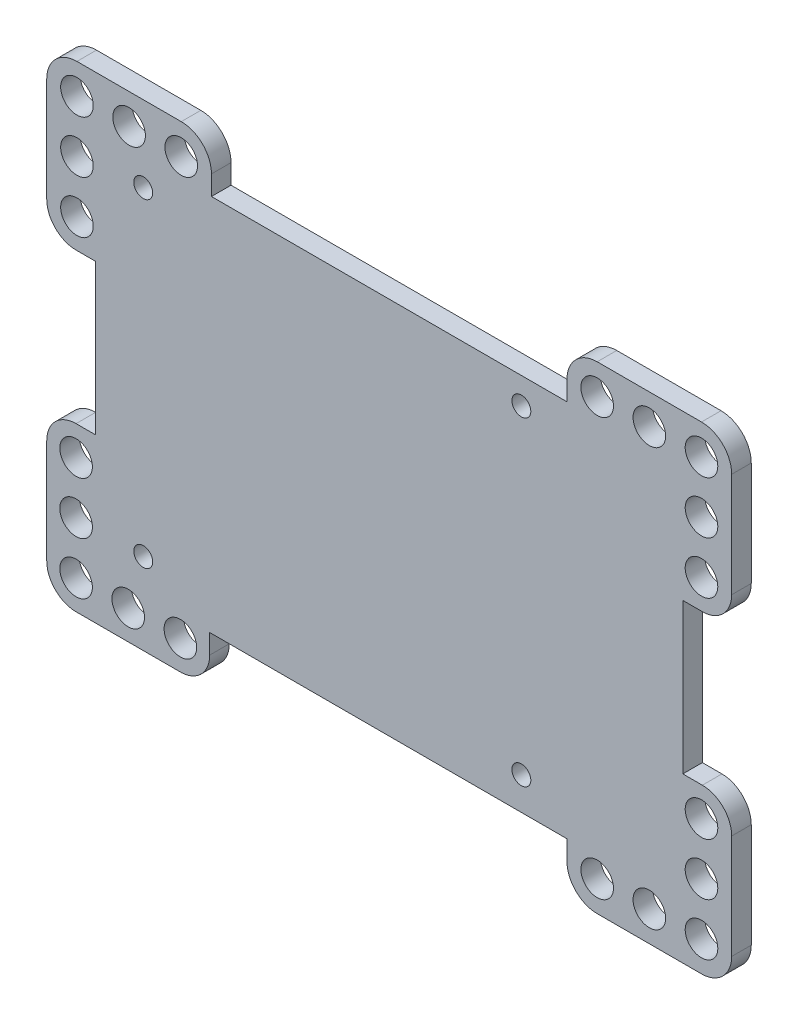
from build123d import *

# Parameters (mm, degrees)
SKETCH_1_R      = 2.5
SKETCH_1_R_2    = 1.45
EXTRUDE_2_DEPTH = 3


with BuildPart() as part:
    # 草圖1 → 填料-伸長2 (new body)
    with BuildSketch(Plane.XY):
        with BuildLine():
            ThreePointArc((-56.198698673, 17.411107553), (-54.880679188, 14.229127038), (-51.698698673, 12.911107553))
            Line((-51.698698673, 12.911107553), (-48.698698673, 12.911107553))
            Line((-48.698698673, 12.911107553), (-48.698698673, -10.138892447))
            Line((-48.698698673, -10.138892447), (-51.698698673, -10.138892447))
            ThreePointArc((-51.698698673, -10.138892447), (-54.880679188, -11.456911932), (-56.198698673, -14.638892447))
            Line((-56.198698673, -14.638892447), (-56.198698673, -30.638892447))
            ThreePointArc((-56.198698673, -30.638892447), (-54.83353613, -33.86732769), (-51.566345732, -35.136945659))
            Line((-51.566345732, -35.136945659), (-35.566345732, -35.136945659))
            ThreePointArc((-35.566345732, -35.136945659), (-32.47026343, -33.773729904), (-31.198698673, -30.638892447))
            Line((-31.198698673, -30.638892447), (-31.198698673, -27.638892447))
            Line((-31.198698673, -27.638892447), (23.601301327, -27.638892447))
            Line((23.601301327, -27.638892447), (23.601301327, -30.638892447))
            ThreePointArc((23.601301327, -30.638892447), (24.958086091, -33.914460625), (28.233654268, -35.271245388))
            Line((28.233654268, -35.271245388), (44.233654268, -35.271245388))
            ThreePointArc((44.233654268, -35.271245388), (47.509222446, -33.914460625), (48.866007209, -30.638892447))
            Line((48.866007209, -30.638892447), (48.866007209, -14.638892447))
            ThreePointArc((48.866007209, -14.638892447), (47.547987725, -11.456911932), (44.366007209, -10.138892447))
            Line((44.366007209, -10.138892447), (41.366007209, -10.138892447))
            Line((41.366007209, -10.138892447), (41.366007209, 12.911107553))
            Line((41.366007209, 12.911107553), (44.366007209, 12.911107553))
            ThreePointArc((44.366007209, 12.911107553), (47.547987725, 14.229127038), (48.866007209, 17.411107553))
            Line((48.866007209, 17.411107553), (48.866007209, 33.411107553))
            ThreePointArc((48.866007209, 33.411107553), (47.509222446, 36.686675731), (44.233654268, 38.043460494))
            Line((44.233654268, 38.043460494), (28.233654268, 38.043460494))
            ThreePointArc((28.233654268, 38.043460494), (24.958086091, 36.686675731), (23.601301327, 33.411107553))
            Line((23.601301327, 33.411107553), (23.601301327, 30.411107553))
            Line((23.601301327, 30.411107553), (-30.933992791, 30.411107553))
            Line((-30.933992791, 30.411107553), (-30.933992791, 33.411107553))
            ThreePointArc((-30.933992791, 33.411107553), (-32.290777554, 36.686675731), (-35.566345732, 38.043460494))
            Line((-35.566345732, 38.043460494), (-51.566345732, 38.043460494))
            ThreePointArc((-51.566345732, 38.043460494), (-54.841913909, 36.686675731), (-56.198698673, 33.411107553))
            Line((-56.198698673, 33.411107553), (-56.198698673, 17.411107553))
        make_face()
        with Locations((-51.698698673, -30.638892447)):
            Circle(SKETCH_1_R, mode=Mode.SUBTRACT)
        with Locations((-43.698698673, -30.638892447)):
            Circle(SKETCH_1_R, mode=Mode.SUBTRACT)
        with Locations((-35.698698673, -30.638892447)):
            Circle(SKETCH_1_R, mode=Mode.SUBTRACT)
        with Locations((-51.698698673, -22.638892447)):
            Circle(SKETCH_1_R, mode=Mode.SUBTRACT)
        with Locations((-41.398698673, -22.638892447)):
            Circle(SKETCH_1_R_2, mode=Mode.SUBTRACT)
        with Locations((-51.698698673, -14.638892447)):
            Circle(SKETCH_1_R, mode=Mode.SUBTRACT)
        with Locations((16.601301327, -22.638892447)):
            Circle(SKETCH_1_R_2, mode=Mode.SUBTRACT)
        with Locations((28.233654268, -30.638892447)):
            Circle(SKETCH_1_R, mode=Mode.SUBTRACT)
        with Locations((36.233654268, -30.638892447)):
            Circle(SKETCH_1_R, mode=Mode.SUBTRACT)
        with Locations((44.233654268, -30.638892447)):
            Circle(SKETCH_1_R, mode=Mode.SUBTRACT)
        with Locations((44.233654268, -22.638892447)):
            Circle(SKETCH_1_R, mode=Mode.SUBTRACT)
        with Locations((44.233654268, -14.638892447)):
            Circle(SKETCH_1_R, mode=Mode.SUBTRACT)
        with Locations((-51.566345732, 17.411107553)):
            Circle(SKETCH_1_R, mode=Mode.SUBTRACT)
        with Locations((-51.566345732, 25.411107553)):
            Circle(SKETCH_1_R, mode=Mode.SUBTRACT)
        with Locations((-41.398698673, 26.361107553)):
            Circle(SKETCH_1_R_2, mode=Mode.SUBTRACT)
        with Locations((-51.566345732, 33.411107553)):
            Circle(SKETCH_1_R, mode=Mode.SUBTRACT)
        with Locations((-43.566345732, 33.411107553)):
            Circle(SKETCH_1_R, mode=Mode.SUBTRACT)
        with Locations((-35.566345732, 33.411107553)):
            Circle(SKETCH_1_R, mode=Mode.SUBTRACT)
        with Locations((44.233654268, 17.411107553)):
            Circle(SKETCH_1_R, mode=Mode.SUBTRACT)
        with Locations((16.601301327, 26.361107553)):
            Circle(SKETCH_1_R_2, mode=Mode.SUBTRACT)
        with Locations((44.233654268, 25.411107553)):
            Circle(SKETCH_1_R, mode=Mode.SUBTRACT)
        with Locations((28.233654268, 33.411107553)):
            Circle(SKETCH_1_R, mode=Mode.SUBTRACT)
        with Locations((36.233654268, 33.411107553)):
            Circle(SKETCH_1_R, mode=Mode.SUBTRACT)
        with Locations((44.233654268, 33.411107553)):
            Circle(SKETCH_1_R, mode=Mode.SUBTRACT)
    extrude(amount=EXTRUDE_2_DEPTH)


solid = part.part
